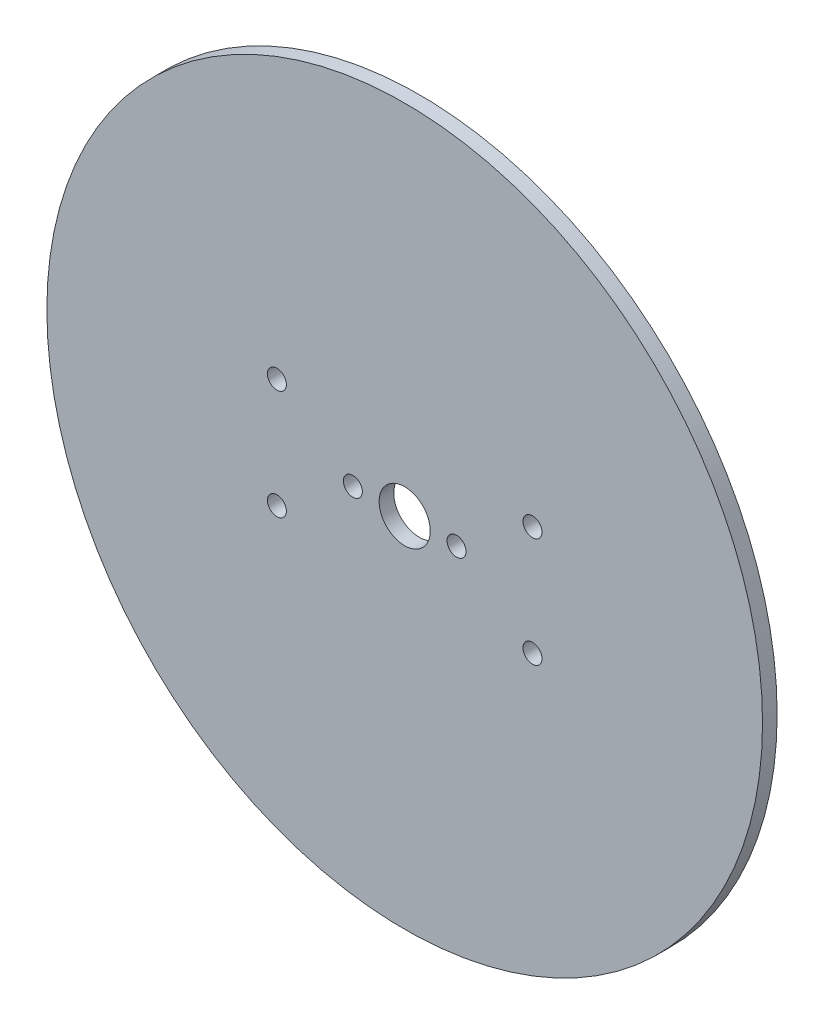
from build123d import *

# Parameters (mm, degrees)
SZKIC1_R                    = 49
DODANIE_WYCI_GNI_CIE1_DEPTH = 2
WYTNIJ_WYCI_GNI_CIE2_REACH  = 4
SZKIC4_R                    = 3.5
OTW_R_POD_RUB_M21_D         = 2.6
OTW_R_POD_RUB_M21_DEPTH     = 2
OTW_R_POD_RUB_M22_D         = 2.6
OTW_R_POD_RUB_M22_DEPTH     = 2


with BuildPart() as part:
    # Szkic1 → Dodanie-wyciągnięcie1 (new body)
    with BuildSketch(Plane.XY):
        Circle(SZKIC1_R)
    extrude(amount=DODANIE_WYCI_GNI_CIE1_DEPTH)

    # Szkic4 → Wytnij-wyciągnięcie2 (cut, up to next)
    with BuildSketch(Plane(origin=(0, 0, 0), x_dir=(-1, 0, 0), z_dir=(0, 0, -1)), mode=Mode.PRIVATE) as wytnij_wyci_gni_cie2_sk1:
        Circle(SZKIC4_R)
    wytnij_wyci_gni_cie2_tool1 = extrude(wytnij_wyci_gni_cie2_sk1.sketch, amount=-WYTNIJ_WYCI_GNI_CIE2_REACH, mode=Mode.PRIVATE) & part.part
    add(wytnij_wyci_gni_cie2_tool1.solids().sort_by_distance((0, 0, 0))[0], mode=Mode.SUBTRACT)

    # Otwór pod śrubę M21
    with Locations(Plane(origin=(-17.5, 7.5, 0), x_dir=(-1, 0, 0), z_dir=(0, 0, -1))):
        with Locations((0, 0), (0, -15), (-35, -15), (-35, 0)):
            Hole(OTW_R_POD_RUB_M21_D / 2, depth=OTW_R_POD_RUB_M21_DEPTH)

    # Otwór pod śrubę M22
    with Locations(Plane(origin=(-7.1, 0, 0), x_dir=(-1, 0, 0), z_dir=(0, 0, -1))):
        with Locations((0, 0), (-14.2, 0)):
            Hole(OTW_R_POD_RUB_M22_D / 2, depth=OTW_R_POD_RUB_M22_DEPTH)


solid = part.part
